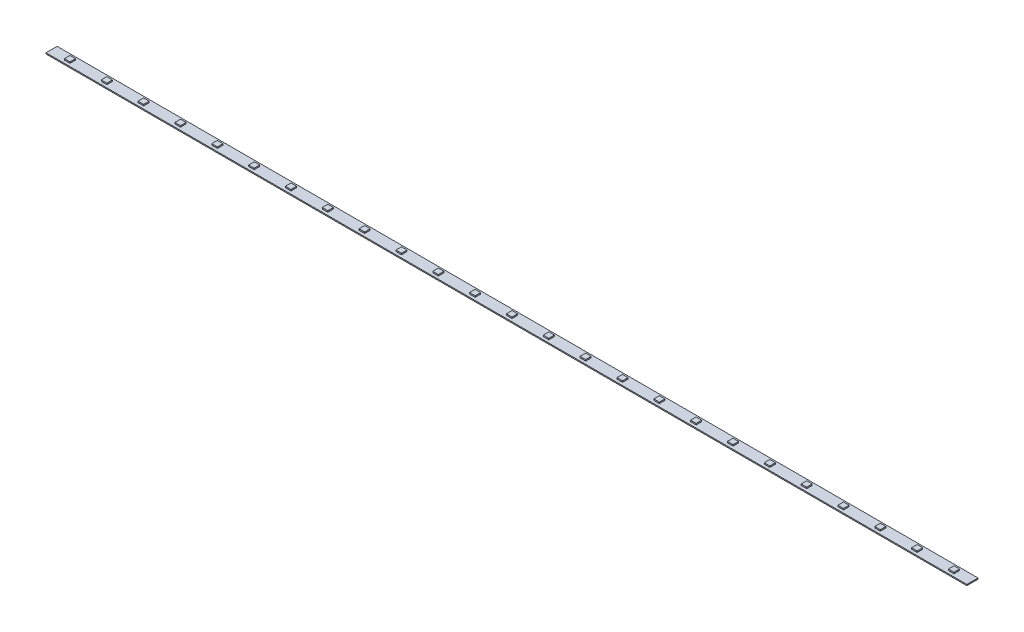
from build123d import *

# Parameters (mm, degrees)
SKETCH1_W           = 33
SKETCH1_H           = 10
BOSS_EXTRUDE1_DEPTH = 1
SKETCH3_W           = 5
SKETCH3_H           = 5
BOSS_EXTRUDE2_DEPTH = 1.2
LPATTERN1_COUNT     = 13
LPATTERN1_PITCH     = 33
LPATTERN1_COL_COUNT = 13
LPATTERN1_COL_PITCH = 33


with BuildPart() as part:
    # Sketch1 → Boss-Extrude1 (new body)
    with BuildSketch(Plane(origin=(0, 0, 0), x_dir=(1, 0, 0), z_dir=(0, 1, 0))):
        Rectangle(SKETCH1_W, SKETCH1_H)
    boss_extrude1 = extrude(amount=BOSS_EXTRUDE1_DEPTH)

    # Sketch3 → Boss-Extrude2 (add)
    with BuildSketch(Plane(origin=(0, 1, 0), x_dir=(1, 0, 0), z_dir=(0, 1, 0))):
        Rectangle(SKETCH3_W, SKETCH3_H)
    boss_extrude2 = extrude(amount=BOSS_EXTRUDE2_DEPTH)

    # LPattern1: Boss-Extrude1, Boss-Extrude2 ×13
    with Locations(*[(-i * LPATTERN1_PITCH, 0, 0) for i in range(1, LPATTERN1_COUNT)]):
        add(boss_extrude1)
        add(boss_extrude2)

    # LPattern1 col: Boss-Extrude1, Boss-Extrude2 ×13
    with Locations(*[(i * LPATTERN1_COL_PITCH, 0, 0) for i in range(1, LPATTERN1_COL_COUNT)]):
        add(boss_extrude1)
        add(boss_extrude2)


solid = part.part
